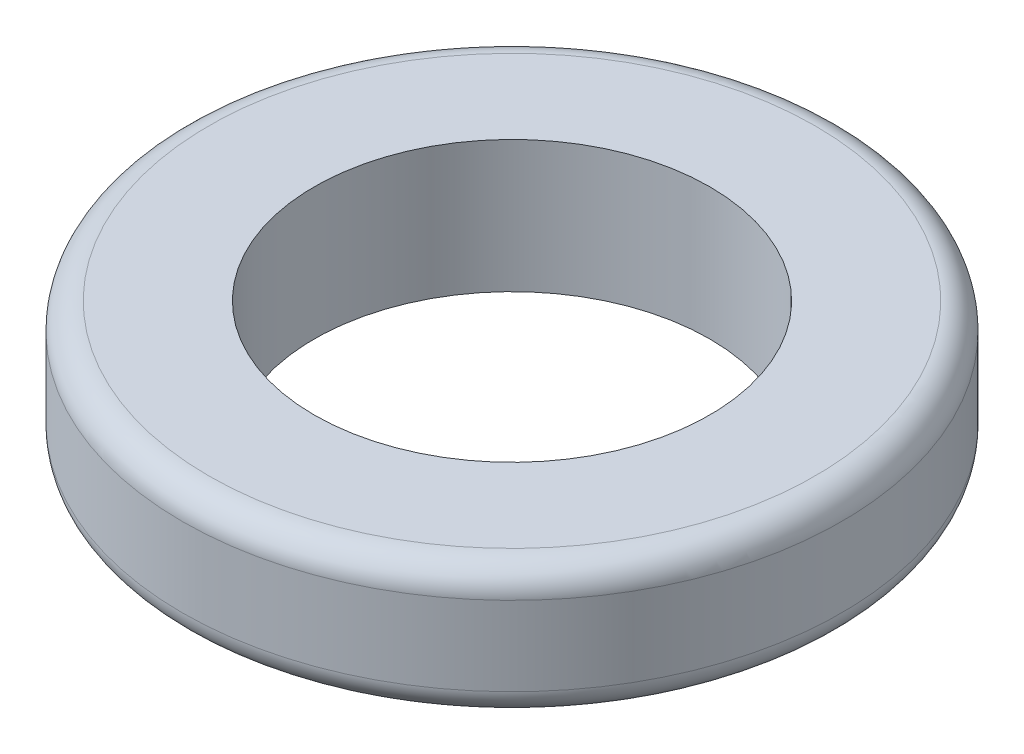
from build123d import *

# Parameters (mm, degrees)
SKETCH1_R           = 12.5
SKETCH1_R_2         = 7.5
BOSS_EXTRUDE1_DEPTH = 5
FILLET1_R           = 1


with BuildPart() as part:
    # Sketch1 → Boss-Extrude1 (new body)
    with BuildSketch(Plane(origin=(0, 0, 0), x_dir=(1, 0, 0), z_dir=(0, 1, 0))):
        Circle(SKETCH1_R)
        Circle(SKETCH1_R_2, mode=Mode.SUBTRACT)
    extrude(amount=BOSS_EXTRUDE1_DEPTH)

    # Fillet1
    fillet1_edges = [part.edges().sort_by_distance(p)[0] for p in [
        (-12.5, 0, 0),
        (-12.5, 5, 0),
    ]]
    fillet(fillet1_edges, radius=FILLET1_R)


solid = part.part
